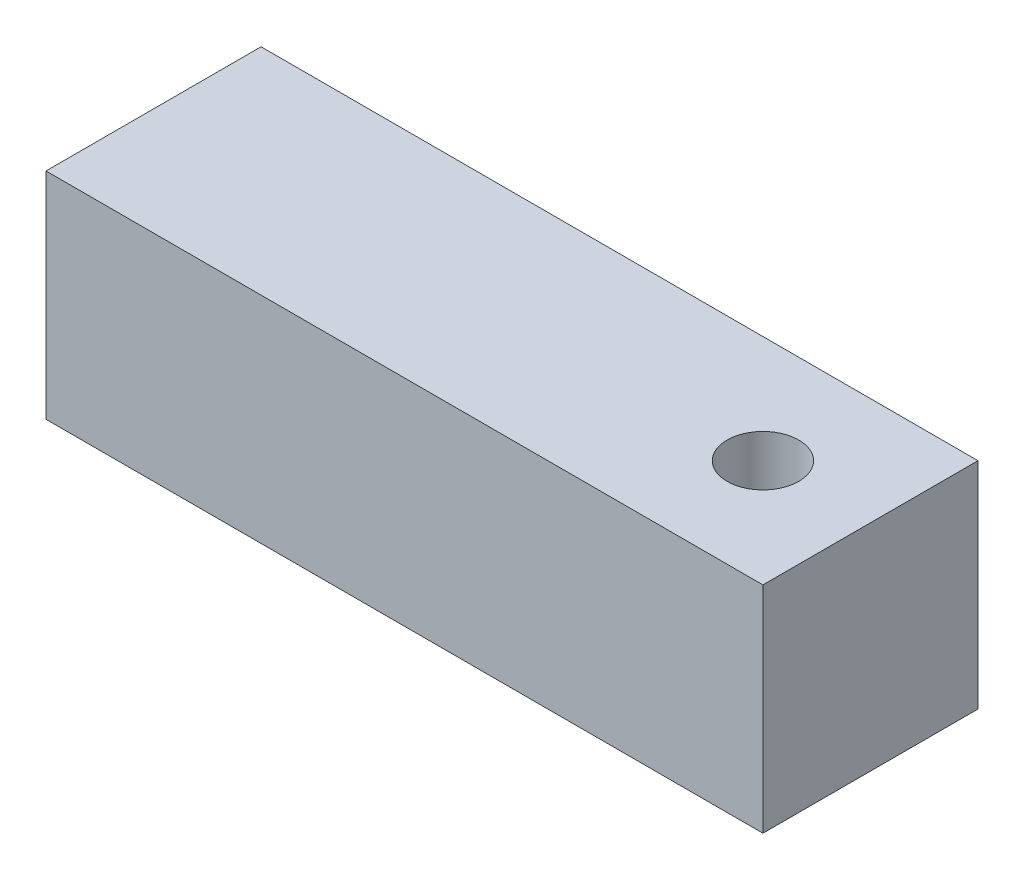
from build123d import *

# Parameters (mm, degrees)
SKETCH1_W           = 50
SKETCH1_H           = 15
SKETCH1_R           = 2.5
BOSS_EXTRUDE1_DEPTH = 15


with BuildPart() as part:
    # Sketch1 → Boss-Extrude1 (new body)
    with BuildSketch(Plane(origin=(0, 0, 0), x_dir=(1, 0, 0), z_dir=(0, 1, 0))):
        with Locations((25, 7.5)):
            Rectangle(SKETCH1_W, SKETCH1_H)
        with Locations((42.5, 7.5)):
            Circle(SKETCH1_R, mode=Mode.SUBTRACT)
    extrude(amount=BOSS_EXTRUDE1_DEPTH)


solid = part.part
